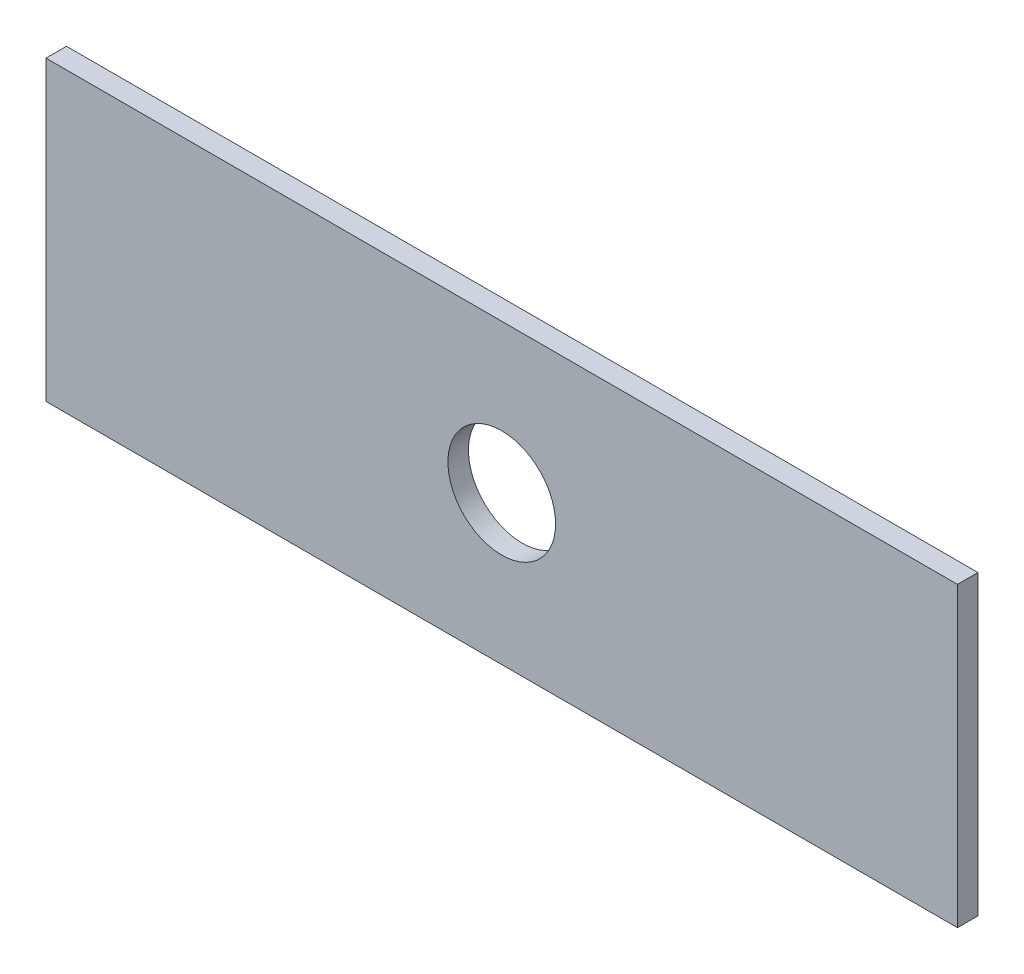
from build123d import *

# Parameters (mm, degrees)
SKETCH2_W           = 177.8
SKETCH2_H           = 58
BOSS_EXTRUDE2_DEPTH = 4
CUT_EXTRUDE1_REACH  = 6
SKETCH3_R           = 10.5


with BuildPart() as part:
    # Sketch2 → Boss-Extrude2 (new body)
    with BuildSketch(Plane.XY):
        with Locations((5.225854908, 0.185980872)):
            Rectangle(SKETCH2_W, SKETCH2_H)
    extrude(amount=BOSS_EXTRUDE2_DEPTH)

    # Sketch3 → Cut-Extrude1 (cut, up to next)
    with BuildSketch(Plane.XY.offset(4), mode=Mode.PRIVATE) as cut_extrude1_sk1:
        with Locations((5.225854908, 0.185980872)):
            Circle(SKETCH3_R)
    cut_extrude1_tool1 = extrude(cut_extrude1_sk1.sketch, amount=-CUT_EXTRUDE1_REACH, mode=Mode.PRIVATE) & part.part
    add(cut_extrude1_tool1.solids().sort_by_distance((5.225855, 0.185981, 4))[0], mode=Mode.SUBTRACT)


solid = part.part
